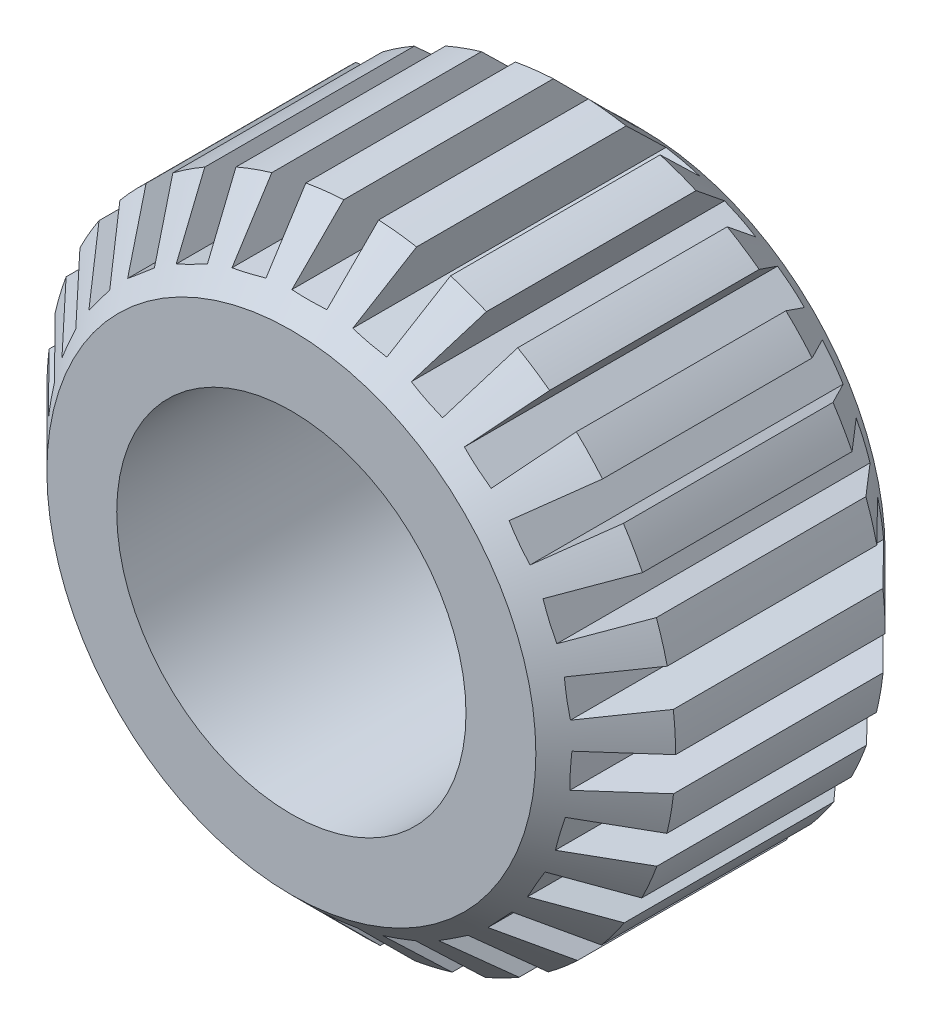
from build123d import *

# Parameters (mm, degrees)
SKETCH1_R           = 9
SKETCH1_R_2         = 5
BOSS_EXTRUDE1_DEPTH = 10
CHAMFER1_SIZE       = 2
CUT_EXTRUDE1_DEPTH  = 11
CIRPATTERN1_COUNT   = 27
SCALE1_SCALE        = 2


with BuildPart() as part:
    # Sketch1 → Boss-Extrude1 (new body)
    with BuildSketch(Plane.XY):
        Circle(SKETCH1_R)
        Circle(SKETCH1_R_2, mode=Mode.SUBTRACT)
    extrude(amount=BOSS_EXTRUDE1_DEPTH)

    # Chamfer1
    chamfer1_edges = [part.edges().sort_by_distance(p)[0] for p in [
        (-9, 0, 0),
        (-9, 0, 10),
    ]]
    chamfer(chamfer1_edges, length=CHAMFER1_SIZE)

    # Sketch2 → Cut-Extrude1 (cut, through all)
    with BuildSketch(Plane.XY):
        with BuildLine():
            Line((0.5, 7.5), (0.5, 8.986100378))
            ThreePointArc((0.5, 8.986100378), (0, 9), (-0.5, 8.986100378))
            Line((-0.5, 8.986100378), (-0.5, 7.5))
            Line((-0.5, 7.5), (0.5, 7.5))
        make_face()
    cut_extrude1 = extrude(amount=CUT_EXTRUDE1_DEPTH, mode=Mode.SUBTRACT)

    # CirPattern1: Cut-Extrude1 ×27 about axis
    cirpattern1_axis = Axis((0, 0, 0), (0, 0, 1))
    for i in range(1, CIRPATTERN1_COUNT):
        add(cut_extrude1.rotate(cirpattern1_axis, i * 360 / CIRPATTERN1_COUNT), mode=Mode.SUBTRACT)


with BuildPart() as part_1:
    # Scale1: scaled about (0, 0, 5)
    add(part.part.scale(SCALE1_SCALE).moved(Location((0, 0, -5))))


solid = part_1.part
